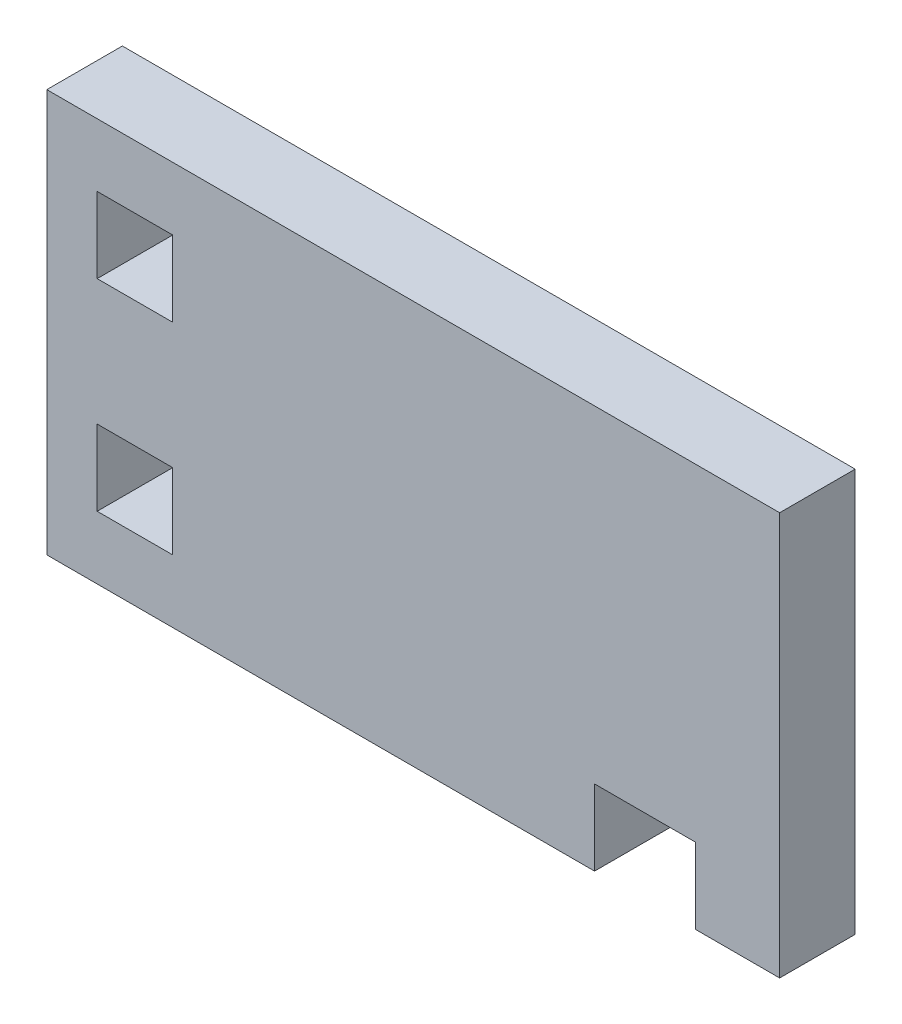
from build123d import *

# Parameters (mm, degrees)
SKETCH1_W           = 15
SKETCH1_H           = 15
BOSS_EXTRUDE1_DEPTH = 15


with BuildPart() as part:
    # Sketch1 → Boss-Extrude1 (new body)
    with BuildSketch(Plane.XY):
        Polygon((0, 0), (0, 80), (145.5, 80), (145.5, 0), (128.75, 0), (128.75, 15), (108.75, 15), (108.75, 0), align=None)
        with Locations((17.5, 60)):
            Rectangle(SKETCH1_W, SKETCH1_H, mode=Mode.SUBTRACT)
        with Locations((17.5, 20)):
            Rectangle(SKETCH1_W, SKETCH1_H, mode=Mode.SUBTRACT)
    extrude(amount=BOSS_EXTRUDE1_DEPTH)


solid = part.part
